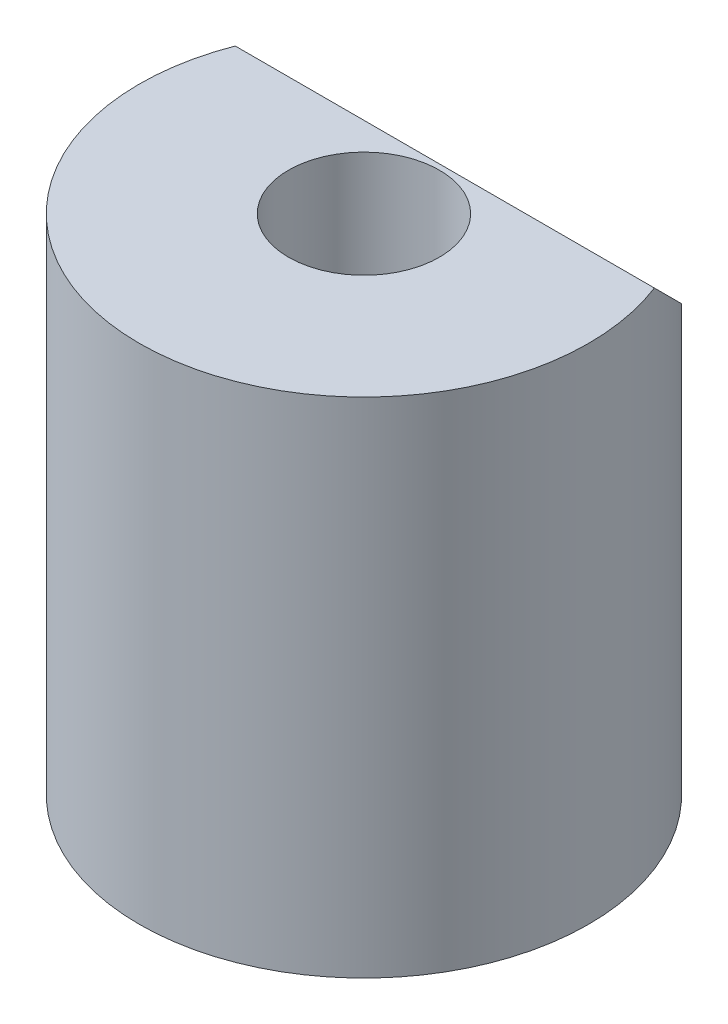
from build123d import *

# Parameters (mm, degrees)
SKETCH1_R           = 6.25
BOSS_EXTRUDE1_DEPTH = 14
SKETCH2_R           = 2.1
CUT_EXTRUDE1_DEPTH  = 12
CUT_EXTRUDE2_DEPTH  = 7


with BuildPart() as part:
    # Sketch1 → Boss-Extrude1 (new body)
    with BuildSketch(Plane(origin=(0, 0, 0), x_dir=(1, 0, 0), z_dir=(0, 1, 0))):
        Circle(SKETCH1_R)
    extrude(amount=BOSS_EXTRUDE1_DEPTH)

    # Sketch2 → Cut-Extrude1 (cut)
    with BuildSketch(Plane(origin=(0, 14, 0), x_dir=(1, 0, 0), z_dir=(0, 1, 0))):
        Circle(SKETCH2_R)
    extrude(amount=-CUT_EXTRUDE1_DEPTH, mode=Mode.SUBTRACT)

    # Sketch3 → Cut-Extrude2 (cut, symmetric)
    with BuildSketch(Plane(origin=(0, 0, 0), x_dir=(0, 0, -1), z_dir=(1, 0, 0))):
        Polygon((2.25, 14), (6.25, 10), (6.25, 14), align=None)
    extrude(amount=CUT_EXTRUDE2_DEPTH, both=True, mode=Mode.SUBTRACT)


solid = part.part
